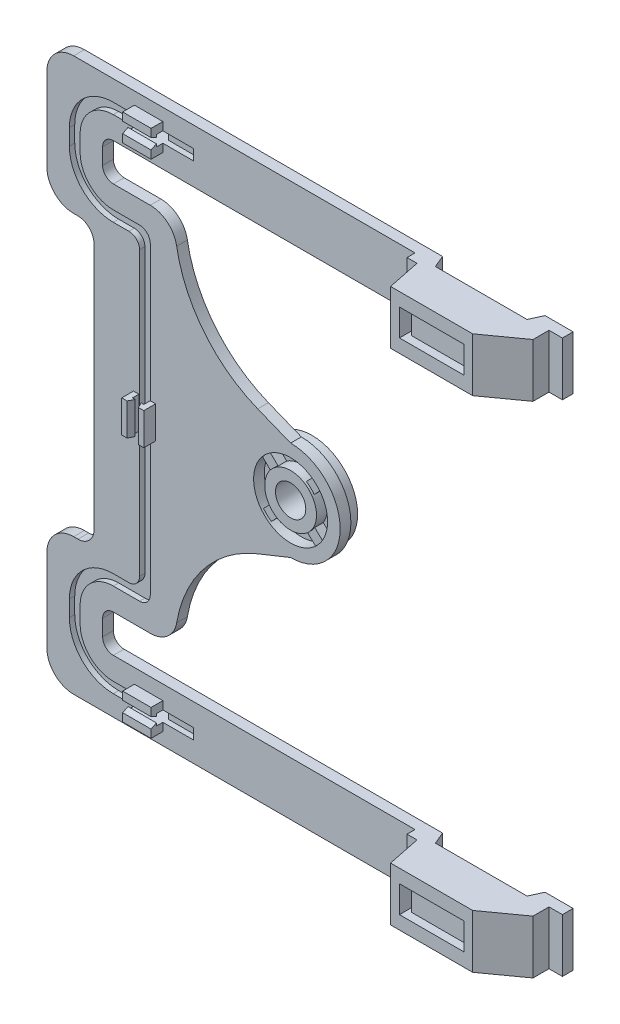
from build123d import *

# Parameters (mm, degrees)
EXTRUDE_1_DEPTH          = 2
SKETCH_3_R               = 2.83
CUT_EXTRUDE_1_DEPTH      = 2
SKETCH_4_R               = 6.9
SKETCH_4_R_2             = 4.83
CUT_EXTRUDE_2_DEPTH      = 2
SKETCH_5_R               = 8.5
EXTRUDE_2_DEPTH          = 2
SKETCH_6_R               = 2.83
CUT_EXTRUDE_3_DEPTH      = 3
CUT_EXTRUDE_4_DEPTH      = 1
SKETCH_8_W               = 5.331630236
SKETCH_8_H               = 2
SKETCH_8_W_2             = 38.23540541
CUT_EXTRUDE_5_DEPTH      = 1
SKETCH_9_W               = 25
SKETCH_9_H               = 10
EXTRUDE_3_DEPTH          = 7.7
SKETCH_10_W              = 19.122636561
SKETCH_10_H              = 1.659866181
CUT_EXTRUDE_6_DEPTH      = 1
CUT_EXTRUDE_6_DEPTH_BACK = 104.185740402
CUT_EXTRUDE_7_DEPTH      = 5
SKETCH_14_W              = 12
SKETCH_14_H              = 5
CUT_EXTRUDE_8_DEPTH      = 1.5
SKETCH_15_W              = 0.75
SKETCH_15_H              = 5
CUT_EXTRUDE_9_DEPTH      = 11.2
SKETCH_16_W              = 5.3
SKETCH_16_H              = 1.5
EXTRUDE_4_DEPTH          = 2.2
EXTRUDE_5_DEPTH          = 5.3
SKETCH_18_W              = 1
SKETCH_18_H              = 6
EXTRUDE_6_DEPTH          = 2.2
EXTRUDE_7_DEPTH          = 6
EXTRUDE_8_DEPTH          = 1.6


with BuildPart() as part:
    # 스케치1 → 보스-돌출1 (new body)
    with BuildSketch(Plane(origin=(0, 0, 0), x_dir=(0, 1, 0), z_dir=(0, 0, 1))):
        with BuildLine():
            Line((41.592870201, -44.934369287), (51.592870201, -44.934369287))
            Line((51.592870201, -44.934369287), (51.592870201, 46.265630713))
            ThreePointArc((51.592870201, 46.265630713), (50.128404107, 49.801164619), (46.592870201, 51.265630713))
            Line((46.592870201, 51.265630713), (31.116453382, 51.265630713))
            ThreePointArc((31.116453382, 51.265630713), (27.580919476, 49.801164619), (26.116453382, 46.265630713))
            Line((26.116453382, 46.265630713), (26.116453382, 45.472212066))
            ThreePointArc((26.116453382, 45.472212066), (25.237773726, 43.350891722), (23.116453382, 42.472212066))
            Line((23.116453382, 42.472212066), (-23.116453382, 42.472212066))
            ThreePointArc((-23.116453382, 42.472212066), (-25.237773726, 43.350891722), (-26.116453382, 45.472212066))
            Line((-26.116453382, 45.472212066), (-26.116453382, 46.265630713))
            ThreePointArc((-26.116453382, 46.265630713), (-27.580919476, 49.801164619), (-31.116453382, 51.265630713))
            Line((-31.116453382, 51.265630713), (-46.592870201, 51.265630713))
            ThreePointArc((-46.592870201, 51.265630713), (-50.128404107, 49.801164619), (-51.592870201, 46.265630713))
            Line((-51.592870201, 46.265630713), (-51.592870201, -44.934369287))
            Line((-51.592870201, -44.934369287), (-41.592870201, -44.934369287))
            Line((-41.592870201, -44.934369287), (-41.592870201, 38.865630713))
            ThreePointArc((-41.592870201, 38.865630713), (-41.007083763, 40.279844275), (-39.592870201, 40.865630713))
            Line((-39.592870201, 40.865630713), (-36.592870201, 40.865630713))
            ThreePointArc((-36.592870201, 40.865630713), (-35.178656639, 40.279844275), (-34.592870201, 38.865630713))
            Line((-34.592870201, 38.865630713), (-34.592870201, 32.165630713))
            Line((-34.592870201, 32.165630713), (-34.592870201, 31.972427496))
            ThreePointArc((-34.592870201, 31.972427496), (-33.414875267, 28.748721977), (-30.435959291, 27.044019965))
            ThreePointArc((-30.435959291, 27.044019965), (-19.104041229, 21.923819296), (-11.712833638, 11.923875686))
            Line((-11.712833638, 11.923875686), (-9.25, 5.785374771))
            ThreePointArc((-9.25, 5.785374771), (0, -3.464625229), (9.25, 5.785374771))
            Line((9.25, 5.785374771), (11.712833638, 11.923875686))
            ThreePointArc((11.712833638, 11.923875686), (19.104041229, 21.923819296), (30.435959291, 27.044019965))
            ThreePointArc((30.435959291, 27.044019965), (33.414875267, 28.748721977), (34.592870201, 31.972427496))
            Line((34.592870201, 31.972427496), (34.592870201, 32.165630713))
            Line((34.592870201, 32.165630713), (34.592870201, 38.865630713))
            ThreePointArc((34.592870201, 38.865630713), (35.178656639, 40.279844275), (36.592870201, 40.865630713))
            Line((36.592870201, 40.865630713), (39.592870201, 40.865630713))
            ThreePointArc((39.592870201, 40.865630713), (41.007083763, 40.279844275), (41.592870201, 38.865630713))
            Line((41.592870201, 38.865630713), (41.592870201, -44.934369287))
        make_face()
    extrude(amount=EXTRUDE_1_DEPTH)

    # 스케치3 → 컷-돌출1 (cut)
    with BuildSketch(Plane.XY.offset(2)):
        with Locations((-5.785374771, 0)):
            Circle(SKETCH_3_R)
    extrude(amount=-CUT_EXTRUDE_1_DEPTH, mode=Mode.SUBTRACT)

    # 스케치4 → 컷-돌출2 (cut)
    with BuildSketch(Plane.XY.offset(2)):
        with Locations((-5.785374771, 0)):
            Circle(SKETCH_4_R)
        with Locations((-5.785374771, 0)):
            Circle(SKETCH_4_R_2, mode=Mode.SUBTRACT)
    extrude(amount=-CUT_EXTRUDE_2_DEPTH, mode=Mode.SUBTRACT)

    # 스케치5 → 보스-돌출2 (add)
    with BuildSketch(Plane(origin=(0, 0, 0), x_dir=(1, 0, 0), z_dir=(0, 0, -1))):
        with Locations((-5.785374771, 0)):
            Circle(SKETCH_5_R)
    extrude(amount=EXTRUDE_2_DEPTH)

    # 스케치6 → 컷-돌출3 (cut, through all)
    with BuildSketch(Plane.XY):
        with Locations((-5.785374771, 0)):
            Circle(SKETCH_6_R)
    extrude(amount=-CUT_EXTRUDE_3_DEPTH, mode=Mode.SUBTRACT)

    # 스케치7 → 컷-돌출4 (cut)
    with BuildSketch(Plane.XY.offset(2)):
        with BuildLine():
            ThreePointArc((-38.865630713, 45.792870201), (-43.249692756, 43.976932244), (-45.065630713, 39.592870201))
            Line((-45.065630713, 39.592870201), (-45.065630713, 36.592870201))
            ThreePointArc((-45.065630713, 36.592870201), (-43.249692756, 32.208808158), (-38.865630713, 30.392870201))
            Line((-38.865630713, 30.392870201), (-33.972427496, 30.392870201))
            ThreePointArc((-33.972427496, 30.392870201), (-32.558213933, 29.807083763), (-31.972427496, 28.392870201))
            Line((-31.972427496, 28.392870201), (-31.972427496, -28.392870201))
            ThreePointArc((-31.972427496, -28.392870201), (-32.558213933, -29.807083763), (-33.972427496, -30.392870201))
            Line((-33.972427496, -30.392870201), (-38.865630713, -30.392870201))
            ThreePointArc((-38.865630713, -30.392870201), (-43.249692756, -32.208808158), (-45.065630713, -36.592870201))
            Line((-45.065630713, -36.592870201), (-45.065630713, -39.592870201))
            ThreePointArc((-45.065630713, -39.592870201), (-43.249692756, -43.976932244), (-38.865630713, -45.792870201))
            Line((-38.865630713, -45.792870201), (-23.865630713, -45.792870201))
            Line((-23.865630713, -45.792870201), (-23.865630713, -47.792870201))
            Line((-23.865630713, -47.792870201), (-38.865630713, -47.792870201))
            ThreePointArc((-38.865630713, -47.792870201), (-44.663906319, -45.391145807), (-47.065630713, -39.592870201))
            Line((-47.065630713, -39.592870201), (-47.065630713, -36.592870201))
            ThreePointArc((-47.065630713, -36.592870201), (-44.663906319, -30.794594595), (-38.865630713, -28.392870201))
            Line((-38.865630713, -28.392870201), (-35.972427496, -28.392870201))
            ThreePointArc((-35.972427496, -28.392870201), (-34.558213933, -27.807083763), (-33.972427496, -26.392870201))
            Line((-33.972427496, -26.392870201), (-33.972427496, 26.392870201))
            ThreePointArc((-33.972427496, 26.392870201), (-34.558213933, 27.807083763), (-35.972427496, 28.392870201))
            Line((-35.972427496, 28.392870201), (-38.865630713, 28.392870201))
            ThreePointArc((-38.865630713, 28.392870201), (-44.663906319, 30.794594595), (-47.065630713, 36.592870201))
            Line((-47.065630713, 36.592870201), (-47.065630713, 39.592870201))
            ThreePointArc((-47.065630713, 39.592870201), (-44.663906319, 45.391145807), (-38.865630713, 47.792870201))
            Line((-38.865630713, 47.792870201), (-23.865630713, 47.792870201))
            Line((-23.865630713, 47.792870201), (-23.865630713, 45.792870201))
            Line((-23.865630713, 45.792870201), (-38.865630713, 45.792870201))
        make_face()
    extrude(amount=-CUT_EXTRUDE_4_DEPTH, mode=Mode.SUBTRACT)

    # 스케치8 → 컷-돌출5 (cut)
    with BuildSketch(Plane(origin=(0, 0, 0), x_dir=(1, 0, 0), z_dir=(0, 0, -1))):
        with Locations((-32.261098575, 46.792870201)):
            Rectangle(SKETCH_8_W, SKETCH_8_H)
        with Locations((8.259291222, 46.792870201)):
            Rectangle(SKETCH_8_W_2, SKETCH_8_H)
        with Locations((8.259291222, -46.792870201)):
            Rectangle(SKETCH_8_W_2, SKETCH_8_H)
        with Locations((-32.261098575, -46.792870201)):
            Rectangle(SKETCH_8_W, SKETCH_8_H)
    extrude(amount=-CUT_EXTRUDE_5_DEPTH, mode=Mode.SUBTRACT)

    # 스케치9 → 보스-돌출3 (add)
    with BuildSketch(Plane.XY.offset(2)):
        with Locations((29.934369287, 46.592870201)):
            Rectangle(SKETCH_9_W, SKETCH_9_H)
        with Locations((29.934369287, -46.592870201)):
            Rectangle(SKETCH_9_W, SKETCH_9_H)
    extrude(amount=EXTRUDE_3_DEPTH)

    # 스케치10 → 컷-돌출6 (cut, two sides)
    with BuildSketch(Plane.XZ.offset(51.592870201)) as cut_extrude_6_sk:
        Polygon((20.568677747, 9.7), (35.881726556, 9.7), (42.434369287, 9.7), (42.434369287, 11.636342053), (17.434369287, 11.636342053), (17.434369287, 9.7), align=None)
        Polygon((19.298815162, 3.494118968), (20.568677747, 9.7), (17.434369287, 9.7), (17.434369287, 3.494118968), align=None)
        Polygon((35.881726556, 9.7), (42.434369287, 4.988237936), (42.434369287, 9.7), align=None)
        with Locations((30.129996028, -0.829933091)):
            Rectangle(SKETCH_10_W, SKETCH_10_H)
        Polygon((21.539749135, 2.3), (20.568677747, 0), (39.691314308, 0), (38.645545121, 2.3), align=None)
    extrude(amount=CUT_EXTRUDE_6_DEPTH, mode=Mode.SUBTRACT)
    extrude(cut_extrude_6_sk.sketch, amount=-CUT_EXTRUDE_6_DEPTH_BACK, mode=Mode.SUBTRACT)

    # 스케치13 → 컷-돌출7 (cut)
    with BuildSketch(Plane(origin=(0, 0, 2.3), x_dir=(1, 0, 0), z_dir=(0, 0, -1))):
        Polygon((21.539749135, -43.592870201), (21.539749135, -49.592870201), (23.539749135, -49.592870201), (36.645545121, -49.592870201), (38.645545121, -49.592870201), (38.645545121, -43.592870201), (36.645545121, -43.592870201), (23.539749135, -43.592870201), align=None)
        Polygon((21.539749135, 49.592870201), (21.539749135, 43.592870201), (23.539749135, 43.592870201), (36.645545121, 43.592870201), (38.645545121, 43.592870201), (38.645545121, 49.592870201), (36.645545121, 49.592870201), (23.539749135, 49.592870201), align=None)
    extrude(amount=-CUT_EXTRUDE_7_DEPTH, mode=Mode.SUBTRACT)

    # 스케치14 → 컷-돌출8 (cut)
    with BuildSketch(Plane.XY.offset(9.7)):
        with Locations((28.231981697, 46.600194241)):
            Rectangle(SKETCH_14_W, SKETCH_14_H)
        with Locations((28.231981697, -46.600194241)):
            Rectangle(SKETCH_14_W, SKETCH_14_H)
    extrude(amount=-CUT_EXTRUDE_8_DEPTH, mode=Mode.SUBTRACT)

    # 스케치15 → 컷-돌출9 (cut, through all)
    with BuildSketch(Plane.XY.offset(8.2)):
        with Locations((22.606981697, 46.600194241)):
            Rectangle(SKETCH_15_W, SKETCH_15_H)
        with Locations((33.856981697, 46.600194241)):
            Rectangle(SKETCH_15_W, SKETCH_15_H)
        with Locations((33.856981697, -46.600194241)):
            Rectangle(SKETCH_15_W, SKETCH_15_H)
        with Locations((22.606981697, -46.600194241)):
            Rectangle(SKETCH_15_W, SKETCH_15_H)
    extrude(amount=-CUT_EXTRUDE_9_DEPTH, mode=Mode.SUBTRACT)

    # 스케치16 → 보스-돌출4 (add)
    with BuildSketch(Plane.XY.offset(2)):
        with Locations((-32.276913693, 48.542870201)):
            Rectangle(SKETCH_16_W, SKETCH_16_H)
        with Locations((-32.276913693, 45.042870201)):
            Rectangle(SKETCH_16_W, SKETCH_16_H)
        with Locations((-32.276913693, -45.042870201)):
            Rectangle(SKETCH_16_W, SKETCH_16_H)
        with Locations((-32.276913693, -48.542870201)):
            Rectangle(SKETCH_16_W, SKETCH_16_H)
    extrude(amount=EXTRUDE_4_DEPTH)

    # 스케치17 → 보스-돌출5 (add)
    with BuildSketch(Plane(origin=(-34.926913693, 0, 0), x_dir=(0, -1, 0), z_dir=(-1, 0, 0))):
        Polygon((-47.792870201, 4.2), (-47.292870201, 3.2), (-47.792870201, 3.2), align=None)
        Polygon((-45.792870201, 4.2), (-46.292870201, 3.2), (-45.792870201, 3.2), align=None)
        Polygon((45.792870201, 4.2), (46.292870201, 3.2), (45.792870201, 3.2), align=None)
        Polygon((47.792870201, 4.2), (47.792870201, 3.2), (47.292870201, 3.2), align=None)
    extrude(amount=-EXTRUDE_5_DEPTH)

    # 스케치18 → 보스-돌출6 (add)
    with BuildSketch(Plane.XY.offset(2)):
        with Locations((-31.472427496, 0)):
            Rectangle(SKETCH_18_W, SKETCH_18_H)
        with Locations((-34.597803464, 0)):
            Rectangle(SKETCH_18_W, SKETCH_18_H)
    extrude(amount=EXTRUDE_6_DEPTH)

    # 스케치19 → 보스-돌출7 (add)
    with BuildSketch(Plane.XZ.offset(3)):
        Polygon((-31.972427496, 4.2), (-32.472427496, 3.2), (-31.972427496, 3.2), align=None)
        Polygon((-34.097803464, 4.2), (-34.097803464, 3.2), (-33.597803464, 3.2), align=None)
    extrude(amount=-EXTRUDE_7_DEPTH)

    # 스케치20 → 보스-돌출8 (add)
    with BuildSketch(Plane.XY):
        with BuildLine():
            ThreePointArc((-10.024835047, 5.443985357), (-10.769059363, 4.772094707), (-11.408050904, 3.999439099))
            Line((-11.408050904, 3.999439099), (-9.889973538, 2.545814009))
            ThreePointArc((-9.889973538, 2.545814009), (-9.273953985, 3.340466295), (-8.506757681, 3.990360267))
            Line((-8.506757681, 3.990360267), (-10.024835047, 5.443985357))
        make_face()
        with BuildLine():
            ThreePointArc((-0.342359383, 4.240705541), (-1.014420285, 4.984776153), (-1.787222074, 5.623590935))
            Line((-1.787222074, 5.623590935), (-3.240917598, 4.105440012))
            ThreePointArc((-3.240917598, 4.105440012), (-2.446061702, 3.489683112), (-1.79591416, 2.722701606))
            Line((-1.79591416, 2.722701606), (-0.342359383, 4.240705541))
        make_face()
        with BuildLine():
            Line((-3.063991862, -3.990360267), (-1.545914496, -5.443985357))
            ThreePointArc((-1.545914496, -5.443985357), (-0.80169018, -4.772094707), (-0.162698639, -3.999439099))
            Line((-0.162698639, -3.999439099), (-1.680776005, -2.545814009))
            ThreePointArc((-1.680776005, -2.545814009), (-2.296795558, -3.340466295), (-3.063991862, -3.990360267))
        make_face()
        with BuildLine():
            ThreePointArc((-11.230329846, -4.238214747), (-10.55860945, -4.982592769), (-9.78610002, -5.621761066))
            Line((-9.78610002, -5.621761066), (-8.332545243, -4.103757131))
            ThreePointArc((-8.332545243, -4.103757131), (-9.126993927, -3.487474935), (-9.776634322, -2.720063823))
            Line((-9.776634322, -2.720063823), (-11.230329846, -4.238214747))
        make_face()
    extrude(amount=EXTRUDE_8_DEPTH)


solid = part.part
